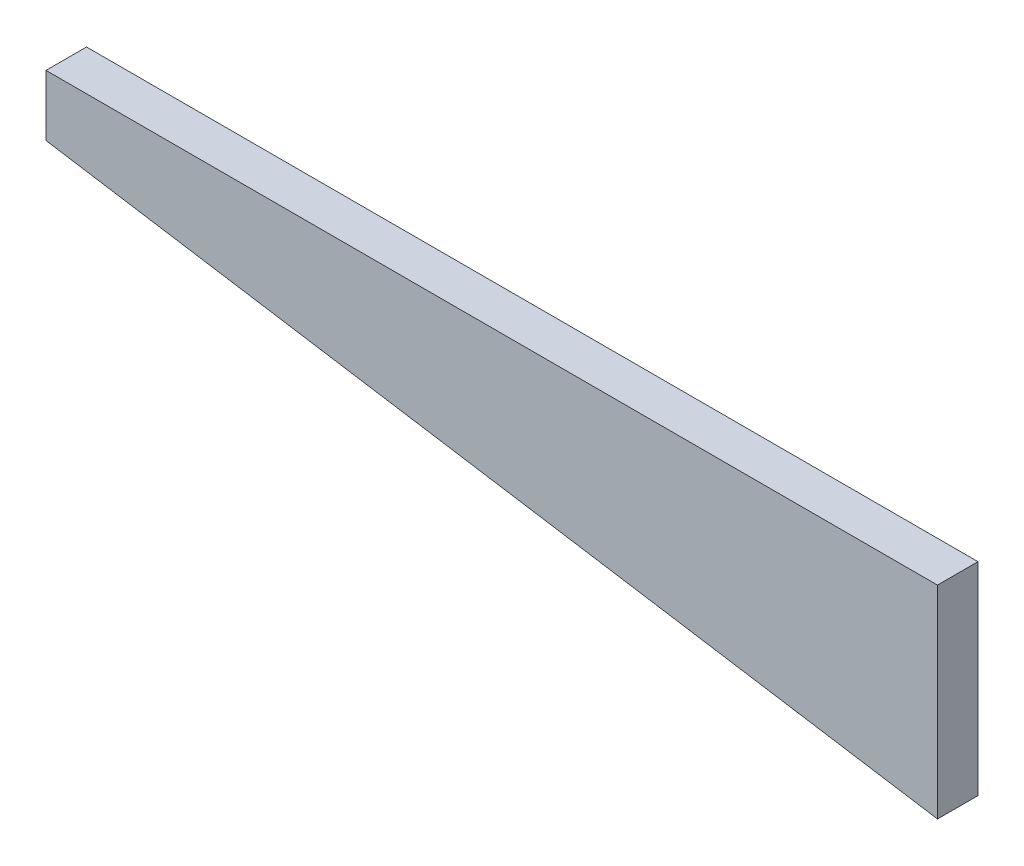
from build123d import *

# Parameters (mm, degrees)
BOSS_EXTRUDE1_DEPTH = 5


with BuildPart() as part:
    # Sketch1 → Boss-Extrude1 (new body, symmetric)
    with BuildSketch(Plane.XY):
        Polygon((0, 0), (0, 50), (-220, 50), (-220, 35), align=None)
    extrude(amount=BOSS_EXTRUDE1_DEPTH, both=True)


solid = part.part
